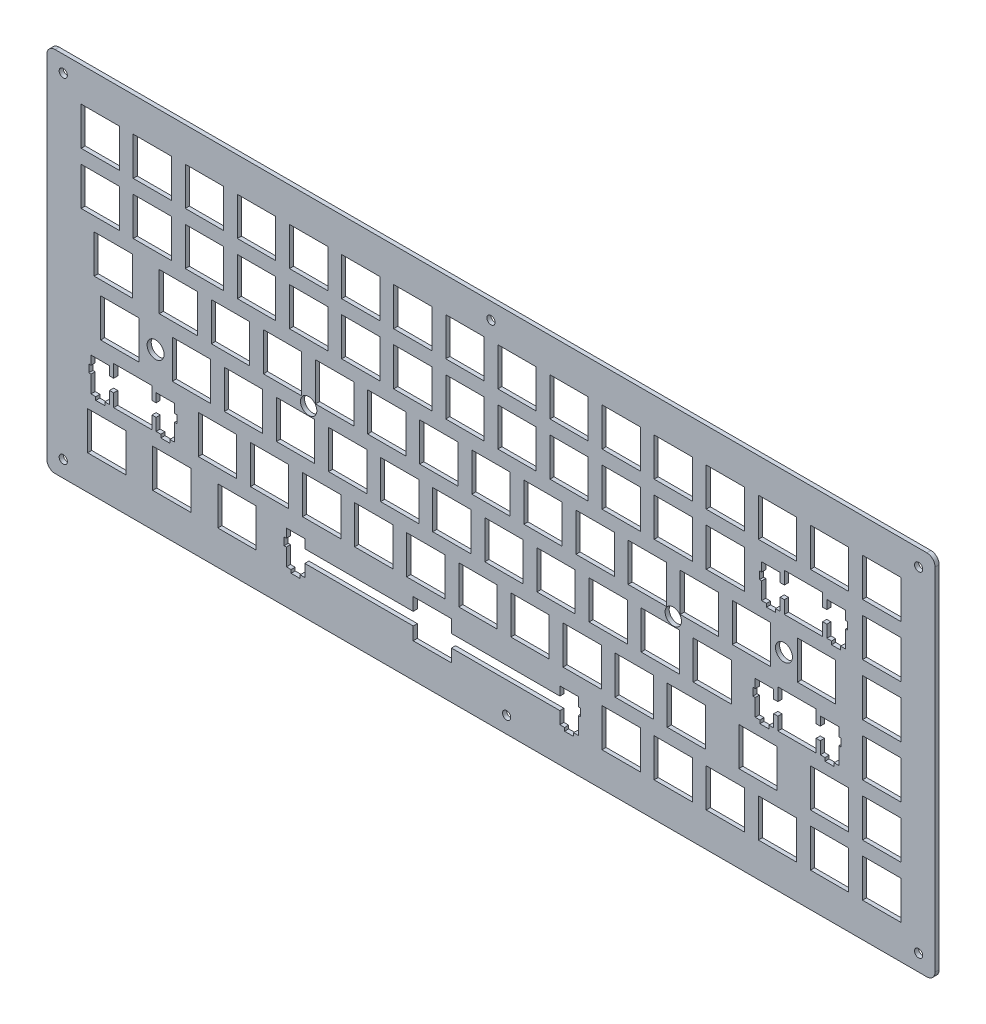
from build123d import *

# Parameters (mm, degrees)
SKETCH_2_R          = 3.1
SKETCH_2_R_2        = 3
SKETCH_2_W          = 13.999
SKETCH_2_H          = 13.99946
SKETCH_2_W_2        = 14.0007
SKETCH_2_W_3        = 13.9994
SKETCH_2_W_4        = 14.00089
SKETCH_2_H_2        = 13.9993
SKETCH_2_W_5        = 14.001
SKETCH_2_H_3        = 13.9992
SKETCH_2_W_6        = 14.0008
SKETCH_2_W_7        = 13.99949
SKETCH_2_W_8        = 13.998
SKETCH_2_W_9        = 13.9989
SKETCH_2_W_10       = 13.9993
SKETCH_2_W_11       = 14.00084
SKETCH_2_W_12       = 14
SKETCH_2_W_13       = 13.99947
SKETCH_2_H_4        = 13.9996
EXTRUDE_1_DEPTH     = 1.5
SKETCH_3_W          = 324.8009154
SKETCH_3_H          = 134.300307
SKETCH_3_W_2        = 304.8009154
SKETCH_3_H_2        = 114.300307
EXTRUDE_3_DEPTH     = 1.5
SKETCH_4_R          = 1.5
CUT_EXTRUDE_1_DEPTH = 1.5
FILLET_1_R          = 3


with BuildPart() as part:
    # 草图2 → 凸台-拉伸1 (new body)
    with BuildSketch(Plane.XY):
        Polygon((302.897, 114.558), (304.896, 114.558), (304.896, 112.557), (304.896, 2.25723), (304.896, 0.257693), (302.897, 0.257693), (2.096, 0.257693), (0.0950846, 0.257693), (0.0950846, 2.25585), (0.0950846, 112.557), (0.0950846, 114.558), (2.096, 114.558), align=None)
        with Locations((259.6505, 66.932)):
            Circle(SKETCH_2_R, mode=Mode.SUBTRACT)
        with Locations((29.86005, 47.882)):
            Circle(SKETCH_2_R, mode=Mode.SUBTRACT)
        with Locations((219.1705, 58.038400001)):
            Circle(SKETCH_2_R_2, mode=Mode.SUBTRACT)
        with Locations((85.82075, 58.038325)):
            Circle(SKETCH_2_R_2, mode=Mode.SUBTRACT)
        Polygon((124.062, 16.7831), (124.062, 12.0826), (84.4381, 12.0826), (84.4381, 15.3128), (77.6884, 15.3128), (77.6884, 12.0826), (76.8629, 12.0826), (76.8629, 9.28384), (77.6884, 9.28384), (77.6884, 3.01377), (79.4135, 3.01377), (79.4135, 1.8135), (82.714, 1.8135), (82.714, 3.01377), (84.4381, 3.01377), (84.4381, 7.48273), (124.062, 7.48273), (124.062, 2.78364), (138.063, 2.78364), (138.063, 7.48273), (177.689, 7.48273), (177.689, 3.01377), (179.414, 3.01377), (179.414, 1.8135), (182.714, 1.8135), (182.714, 3.01377), (184.438, 3.01377), (184.438, 9.28384), (185.263, 9.28384), (185.263, 12.0826), (184.438, 12.0826), (184.438, 15.3128), (177.689, 15.3128), (177.689, 12.0826), (138.063, 12.0826), (138.063, 16.7831), align=None, mode=Mode.SUBTRACT)
        with Locations((295.3705, 9.78337)):
            Rectangle(SKETCH_2_W, SKETCH_2_H, mode=Mode.SUBTRACT)
        with Locations((276.3205, 9.78337)):
            Rectangle(SKETCH_2_W, SKETCH_2_H, mode=Mode.SUBTRACT)
        with Locations((257.2705, 9.78337)):
            Rectangle(SKETCH_2_W, SKETCH_2_H, mode=Mode.SUBTRACT)
        with Locations((238.2205, 9.78337)):
            Rectangle(SKETCH_2_W, SKETCH_2_H, mode=Mode.SUBTRACT)
        with Locations((219.1705, 9.78337)):
            Rectangle(SKETCH_2_W, SKETCH_2_H, mode=Mode.SUBTRACT)
        with Locations((200.1205, 9.78337)):
            Rectangle(SKETCH_2_W, SKETCH_2_H, mode=Mode.SUBTRACT)
        with Locations((59.62635, 9.78337)):
            Rectangle(SKETCH_2_W_2, SKETCH_2_H, mode=Mode.SUBTRACT)
        with Locations((35.8131, 9.78337)):
            Rectangle(SKETCH_2_W_3, SKETCH_2_H, mode=Mode.SUBTRACT)
        with Locations((12.001355, 9.78337)):
            Rectangle(SKETCH_2_W_4, SKETCH_2_H, mode=Mode.SUBTRACT)
        Polygon((14.5259, 35.8316), (14.5259, 31.1326), (13.0018, 31.1326), (13.0018, 34.3628), (6.25217, 34.3628), (6.25217, 31.1326), (5.42671, 31.1326), (5.42671, 28.3325), (6.25217, 28.3325), (6.25217, 22.0638), (7.97609, 22.0638), (7.97609, 20.8621), (11.2765, 20.8621), (11.2765, 22.0638), (13.0018, 22.0638), (13.0018, 26.5327), (14.5259, 26.5327), (14.5259, 21.8323), (28.5268, 21.8323), (28.5268, 26.5327), (30.0509, 26.5327), (30.0509, 22.0638), (31.7762, 22.0638), (31.7762, 20.8621), (35.0766, 20.8621), (35.0766, 22.0638), (36.8018, 22.0638), (36.8018, 28.3325), (37.6259, 28.3325), (37.6259, 31.1326), (36.8018, 31.1326), (36.8018, 34.3628), (30.0509, 34.3628), (30.0509, 31.1326), (28.5268, 31.1326), (28.5268, 35.8316), align=None, mode=Mode.SUBTRACT)
        with Locations((295.3705, 28.83195)):
            Rectangle(SKETCH_2_W, SKETCH_2_H_2, mode=Mode.SUBTRACT)
        with Locations((276.3205, 28.83195)):
            Rectangle(SKETCH_2_W, SKETCH_2_H_2, mode=Mode.SUBTRACT)
        with Locations((250.1265, 28.83195)):
            Rectangle(SKETCH_2_W_5, SKETCH_2_H_2, mode=Mode.SUBTRACT)
        with Locations((223.9325, 28.83195)):
            Rectangle(SKETCH_2_W_5, SKETCH_2_H_2, mode=Mode.SUBTRACT)
        with Locations((204.8825, 28.83195)):
            Rectangle(SKETCH_2_W_5, SKETCH_2_H_2, mode=Mode.SUBTRACT)
        with Locations((185.8325, 28.83195)):
            Rectangle(SKETCH_2_W_5, SKETCH_2_H_2, mode=Mode.SUBTRACT)
        with Locations((166.7825, 28.83195)):
            Rectangle(SKETCH_2_W_5, SKETCH_2_H_2, mode=Mode.SUBTRACT)
        with Locations((147.7325, 28.83195)):
            Rectangle(SKETCH_2_W_5, SKETCH_2_H_2, mode=Mode.SUBTRACT)
        with Locations((128.6825, 28.83195)):
            Rectangle(SKETCH_2_W_5, SKETCH_2_H_2, mode=Mode.SUBTRACT)
        with Locations((109.6325, 28.83195)):
            Rectangle(SKETCH_2_W_5, SKETCH_2_H_2, mode=Mode.SUBTRACT)
        with Locations((90.58255, 28.83195)):
            Rectangle(SKETCH_2_W_2, SKETCH_2_H_2, mode=Mode.SUBTRACT)
        with Locations((71.53255, 28.83195)):
            Rectangle(SKETCH_2_W_2, SKETCH_2_H_2, mode=Mode.SUBTRACT)
        with Locations((52.48255, 28.83195)):
            Rectangle(SKETCH_2_W_2, SKETCH_2_H_2, mode=Mode.SUBTRACT)
        Polygon((257.413, 54.8816), (257.413, 50.1826), (255.888, 50.1826), (255.888, 53.4127), (249.138, 53.4127), (249.138, 50.1826), (248.313, 50.1826), (248.313, 47.3826), (249.138, 47.3826), (249.138, 41.1124), (250.863, 41.1124), (250.863, 39.9122), (254.163, 39.9122), (254.163, 41.1124), (255.888, 41.1124), (255.888, 45.5828), (257.413, 45.5828), (257.413, 40.8824), (271.413, 40.8824), (271.413, 45.5828), (272.939, 45.5828), (272.939, 41.1124), (274.664, 41.1124), (274.664, 39.9122), (277.964, 39.9122), (277.964, 41.1124), (279.688, 41.1124), (279.688, 47.3826), (280.513, 47.3826), (280.513, 50.1826), (279.688, 50.1826), (279.688, 53.4127), (272.939, 53.4127), (272.939, 50.1826), (271.413, 50.1826), (271.413, 54.8816), align=None, mode=Mode.SUBTRACT)
        with Locations((295.3705, 47.882)):
            Rectangle(SKETCH_2_W, SKETCH_2_H_3, mode=Mode.SUBTRACT)
        with Locations((233.4575, 47.882)):
            Rectangle(SKETCH_2_W_5, SKETCH_2_H_3, mode=Mode.SUBTRACT)
        with Locations((214.4075, 47.882)):
            Rectangle(SKETCH_2_W_5, SKETCH_2_H_3, mode=Mode.SUBTRACT)
        with Locations((195.3575, 47.882)):
            Rectangle(SKETCH_2_W_5, SKETCH_2_H_3, mode=Mode.SUBTRACT)
        with Locations((176.3075, 47.882)):
            Rectangle(SKETCH_2_W_5, SKETCH_2_H_3, mode=Mode.SUBTRACT)
        with Locations((157.2575, 47.882)):
            Rectangle(SKETCH_2_W_5, SKETCH_2_H_3, mode=Mode.SUBTRACT)
        with Locations((138.2075, 47.882)):
            Rectangle(SKETCH_2_W_5, SKETCH_2_H_3, mode=Mode.SUBTRACT)
        with Locations((119.1575, 47.882)):
            Rectangle(SKETCH_2_W_5, SKETCH_2_H_3, mode=Mode.SUBTRACT)
        with Locations((100.1076, 47.882)):
            Rectangle(SKETCH_2_W_6, SKETCH_2_H_3, mode=Mode.SUBTRACT)
        with Locations((81.05755, 47.882)):
            Rectangle(SKETCH_2_W_2, SKETCH_2_H_3, mode=Mode.SUBTRACT)
        with Locations((62.00755, 47.882)):
            Rectangle(SKETCH_2_W_2, SKETCH_2_H_3, mode=Mode.SUBTRACT)
        with Locations((42.95755, 47.882)):
            Rectangle(SKETCH_2_W_2, SKETCH_2_H_3, mode=Mode.SUBTRACT)
        with Locations((16.763155, 47.882)):
            Rectangle(SKETCH_2_W_7, SKETCH_2_H_3, mode=Mode.SUBTRACT)
        with Locations((295.3705, 66.932)):
            Rectangle(SKETCH_2_W, SKETCH_2_H_3, mode=Mode.SUBTRACT)
        with Locations((271.5575, 66.932)):
            Rectangle(SKETCH_2_W_5, SKETCH_2_H_3, mode=Mode.SUBTRACT)
        with Locations((247.745, 66.932)):
            Rectangle(SKETCH_2_W_8, SKETCH_2_H_3, mode=Mode.SUBTRACT)
        with Locations((228.6955, 66.932)):
            Rectangle(SKETCH_2_W, SKETCH_2_H_3, mode=Mode.SUBTRACT)
        with Locations((209.6455, 66.932)):
            Rectangle(SKETCH_2_W, SKETCH_2_H_3, mode=Mode.SUBTRACT)
        with Locations((190.5955, 66.932)):
            Rectangle(SKETCH_2_W, SKETCH_2_H_3, mode=Mode.SUBTRACT)
        with Locations((171.5455, 66.932)):
            Rectangle(SKETCH_2_W, SKETCH_2_H_3, mode=Mode.SUBTRACT)
        with Locations((152.4955, 66.932)):
            Rectangle(SKETCH_2_W, SKETCH_2_H_3, mode=Mode.SUBTRACT)
        with Locations((133.4455, 66.932)):
            Rectangle(SKETCH_2_W, SKETCH_2_H_3, mode=Mode.SUBTRACT)
        with Locations((114.3955, 66.932)):
            Rectangle(SKETCH_2_W, SKETCH_2_H_3, mode=Mode.SUBTRACT)
        with Locations((95.34555, 66.932)):
            Rectangle(SKETCH_2_W_9, SKETCH_2_H_3, mode=Mode.SUBTRACT)
        with Locations((76.29575, 66.932)):
            Rectangle(SKETCH_2_W_10, SKETCH_2_H_3, mode=Mode.SUBTRACT)
        with Locations((57.24575, 66.932)):
            Rectangle(SKETCH_2_W_10, SKETCH_2_H_3, mode=Mode.SUBTRACT)
        with Locations((38.1957, 66.932)):
            Rectangle(SKETCH_2_W_3, SKETCH_2_H_3, mode=Mode.SUBTRACT)
        with Locations((14.38258, 66.932)):
            Rectangle(SKETCH_2_W_11, SKETCH_2_H_3, mode=Mode.SUBTRACT)
        Polygon((259.796, 92.9816), (259.796, 88.2826), (258.27, 88.2826), (258.27, 91.5127), (251.521, 91.5127), (251.521, 88.2826), (250.696, 88.2826), (250.696, 85.4826), (251.521, 85.4826), (251.521, 79.2124), (253.245, 79.2124), (253.245, 78.0122), (256.545, 78.0122), (256.545, 79.2124), (258.27, 79.2124), (258.27, 83.6828), (259.796, 83.6828), (259.796, 78.9824), (273.795, 78.9824), (273.795, 83.6828), (275.321, 83.6828), (275.321, 79.2124), (277.045, 79.2124), (277.045, 78.0122), (280.345, 78.0122), (280.345, 79.2124), (282.071, 79.2124), (282.071, 85.4826), (282.896, 85.4826), (282.896, 88.2826), (282.071, 88.2826), (282.071, 91.5127), (275.321, 91.5127), (275.321, 88.2826), (273.795, 88.2826), (273.795, 92.9816), align=None, mode=Mode.SUBTRACT)
        with Locations((295.3705, 85.982)):
            Rectangle(SKETCH_2_W, SKETCH_2_H_3, mode=Mode.SUBTRACT)
        with Locations((238.2205, 85.982)):
            Rectangle(SKETCH_2_W, SKETCH_2_H_3, mode=Mode.SUBTRACT)
        with Locations((219.1705, 85.982)):
            Rectangle(SKETCH_2_W, SKETCH_2_H_3, mode=Mode.SUBTRACT)
        with Locations((200.1205, 85.982)):
            Rectangle(SKETCH_2_W, SKETCH_2_H_3, mode=Mode.SUBTRACT)
        with Locations((181.0705, 85.982)):
            Rectangle(SKETCH_2_W, SKETCH_2_H_3, mode=Mode.SUBTRACT)
        with Locations((162.0205, 85.982)):
            Rectangle(SKETCH_2_W, SKETCH_2_H_3, mode=Mode.SUBTRACT)
        with Locations((142.9705, 85.982)):
            Rectangle(SKETCH_2_W, SKETCH_2_H_3, mode=Mode.SUBTRACT)
        with Locations((123.92, 85.982)):
            Rectangle(SKETCH_2_W_12, SKETCH_2_H_3, mode=Mode.SUBTRACT)
        with Locations((104.86935, 85.982)):
            Rectangle(SKETCH_2_W_10, SKETCH_2_H_3, mode=Mode.SUBTRACT)
        with Locations((85.82075, 85.982)):
            Rectangle(SKETCH_2_W_10, SKETCH_2_H_3, mode=Mode.SUBTRACT)
        with Locations((66.77075, 85.982)):
            Rectangle(SKETCH_2_W_10, SKETCH_2_H_3, mode=Mode.SUBTRACT)
        with Locations((47.72075, 85.982)):
            Rectangle(SKETCH_2_W_10, SKETCH_2_H_3, mode=Mode.SUBTRACT)
        with Locations((28.6707, 85.982)):
            Rectangle(SKETCH_2_W_3, SKETCH_2_H_3, mode=Mode.SUBTRACT)
        with Locations((9.620765, 85.982)):
            Rectangle(SKETCH_2_W_13, SKETCH_2_H_3, mode=Mode.SUBTRACT)
        with Locations((295.3705, 105.0322)):
            Rectangle(SKETCH_2_W, SKETCH_2_H_4, mode=Mode.SUBTRACT)
        with Locations((276.3205, 105.0322)):
            Rectangle(SKETCH_2_W, SKETCH_2_H_4, mode=Mode.SUBTRACT)
        with Locations((257.2705, 105.0322)):
            Rectangle(SKETCH_2_W, SKETCH_2_H_4, mode=Mode.SUBTRACT)
        with Locations((238.2205, 105.0322)):
            Rectangle(SKETCH_2_W, SKETCH_2_H_4, mode=Mode.SUBTRACT)
        with Locations((219.1705, 105.0322)):
            Rectangle(SKETCH_2_W, SKETCH_2_H_4, mode=Mode.SUBTRACT)
        with Locations((200.1205, 105.0322)):
            Rectangle(SKETCH_2_W, SKETCH_2_H_4, mode=Mode.SUBTRACT)
        with Locations((181.0705, 105.0322)):
            Rectangle(SKETCH_2_W, SKETCH_2_H_4, mode=Mode.SUBTRACT)
        with Locations((162.0205, 105.0322)):
            Rectangle(SKETCH_2_W, SKETCH_2_H_4, mode=Mode.SUBTRACT)
        with Locations((142.9705, 105.0322)):
            Rectangle(SKETCH_2_W, SKETCH_2_H_4, mode=Mode.SUBTRACT)
        with Locations((123.92, 105.0322)):
            Rectangle(SKETCH_2_W_12, SKETCH_2_H_4, mode=Mode.SUBTRACT)
        with Locations((104.86935, 105.0322)):
            Rectangle(SKETCH_2_W_10, SKETCH_2_H_4, mode=Mode.SUBTRACT)
        with Locations((85.82075, 105.0322)):
            Rectangle(SKETCH_2_W_10, SKETCH_2_H_4, mode=Mode.SUBTRACT)
        with Locations((66.77075, 105.0322)):
            Rectangle(SKETCH_2_W_10, SKETCH_2_H_4, mode=Mode.SUBTRACT)
        with Locations((47.72075, 105.0322)):
            Rectangle(SKETCH_2_W_10, SKETCH_2_H_4, mode=Mode.SUBTRACT)
        with Locations((28.6707, 105.0322)):
            Rectangle(SKETCH_2_W_3, SKETCH_2_H_4, mode=Mode.SUBTRACT)
        with Locations((9.620765, 105.0322)):
            Rectangle(SKETCH_2_W_13, SKETCH_2_H_4, mode=Mode.SUBTRACT)
    extrude(amount=EXTRUDE_1_DEPTH)

    # 草图3 → 凸台-拉伸3 (add)
    with BuildSketch(Plane.XY.offset(1.5)):
        with Locations((152.4955423, 57.4078465)):
            Rectangle(SKETCH_3_W, SKETCH_3_H)
        with Locations((152.4955423, 57.4078465)):
            Rectangle(SKETCH_3_W_2, SKETCH_3_H_2, mode=Mode.SUBTRACT)
    extrude(amount=-EXTRUDE_3_DEPTH)

    # 草图4 → 切除-拉伸1 (cut)
    with BuildSketch(Plane.XY.offset(1.5)):
        with Locations((-3.9049154, 118.558)):
            Circle(SKETCH_4_R)
        with Locations((152.4955423, 118.558)):
            Circle(SKETCH_4_R)
        with Locations((308.896, 118.558)):
            Circle(SKETCH_4_R)
        with Locations((-3.9049154, -3.742307)):
            Circle(SKETCH_4_R)
        with Locations((158.236443404, -3.742307)):
            Circle(SKETCH_4_R)
        with Locations((308.896, -3.742307)):
            Circle(SKETCH_4_R)
    extrude(amount=-CUT_EXTRUDE_1_DEPTH, mode=Mode.SUBTRACT)

    # 圆角1
    fillet_1_edges = [part.edges().sort_by_distance(p)[0] for p in [
        (-9.9049154, -9.742307, 0.75),
        (-9.9049154, 124.558, 0.75),
        (314.896, 124.558, 0.75),
        (314.896, -9.742307, 0.75),
    ]]
    fillet(fillet_1_edges, radius=FILLET_1_R)


solid = part.part
